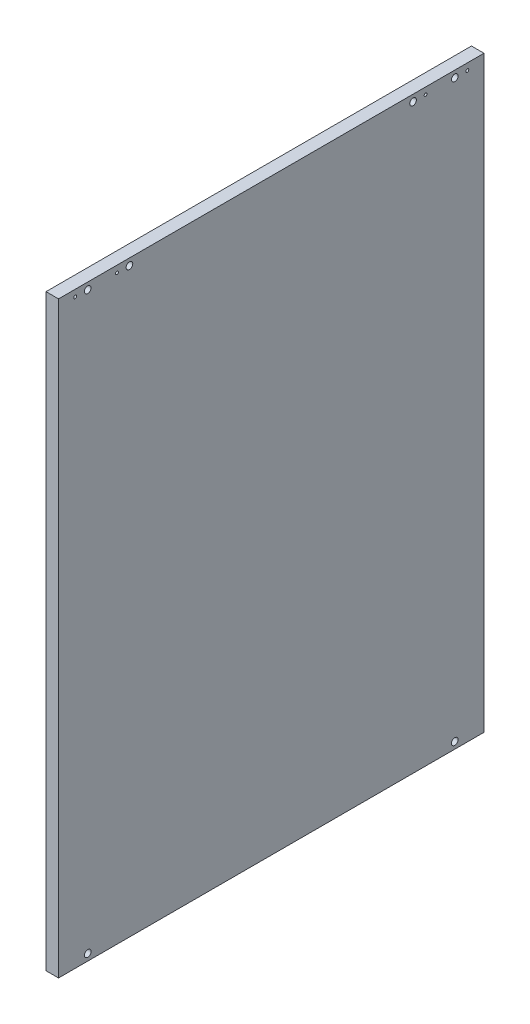
from build123d import *

# Parameters (mm, degrees)
SKETCH_1_W          = 510
SKETCH_1_H          = 705
EXTRUDE_1_DEPTH     = 15
SKETCH_257_R        = 4
CUT_EXTRUDE_3_DEPTH = 10
SKETCH_750_R        = 1.75
CUT_EXTRUDE_4_DEPTH = 15


with BuildPart() as part:
    # Эскиз1 → Вытянуть1 (new body)
    with BuildSketch(Plane(origin=(0, 0, 0), x_dir=(0, 0, -1), z_dir=(1, 0, 0))):
        with Locations((255, 352.5)):
            Rectangle(SKETCH_1_W, SKETCH_1_H)
    extrude(amount=EXTRUDE_1_DEPTH)

    # Sketch 257 → Вырез-Вытянуть3 (cut)
    with BuildSketch(Plane(origin=(15, 0, 0), x_dir=(0, 0, -1), z_dir=(1, 0, 0))):
        with Locations(Location((425, 697, 0), (0, 0, 180))):  # turned: the seam where the file's is
            Circle(SKETCH_257_R)
        with Locations(Location((475, 697, 0), (0, 0, 180))):  # turned: the seam where the file's is
            Circle(SKETCH_257_R)
        with Locations((35, 697)):
            Circle(SKETCH_257_R)
        with Locations((85, 697)):
            Circle(SKETCH_257_R)
        with Locations((35, 8)):
            Circle(SKETCH_257_R)
        with Locations((475, 8)):
            Circle(SKETCH_257_R)
    extrude(amount=-CUT_EXTRUDE_3_DEPTH, mode=Mode.SUBTRACT)

    # Sketch 750 → Вырез-Вытянуть4 (cut)
    with BuildSketch(Plane(origin=(15, 0, 0), x_dir=(0, 0, -1), z_dir=(1, 0, 0))):
        with Locations(Location((440, 697, 0), (0, 0, 180))):  # turned: the seam where the file's is
            Circle(SKETCH_750_R)
        with Locations(Location((490, 697, 0), (0, 0, 180))):  # turned: the seam where the file's is
            Circle(SKETCH_750_R)
        with Locations((20, 697)):
            Circle(SKETCH_750_R)
        with Locations((70, 697)):
            Circle(SKETCH_750_R)
    extrude(amount=-CUT_EXTRUDE_4_DEPTH, mode=Mode.SUBTRACT)


solid = part.part
